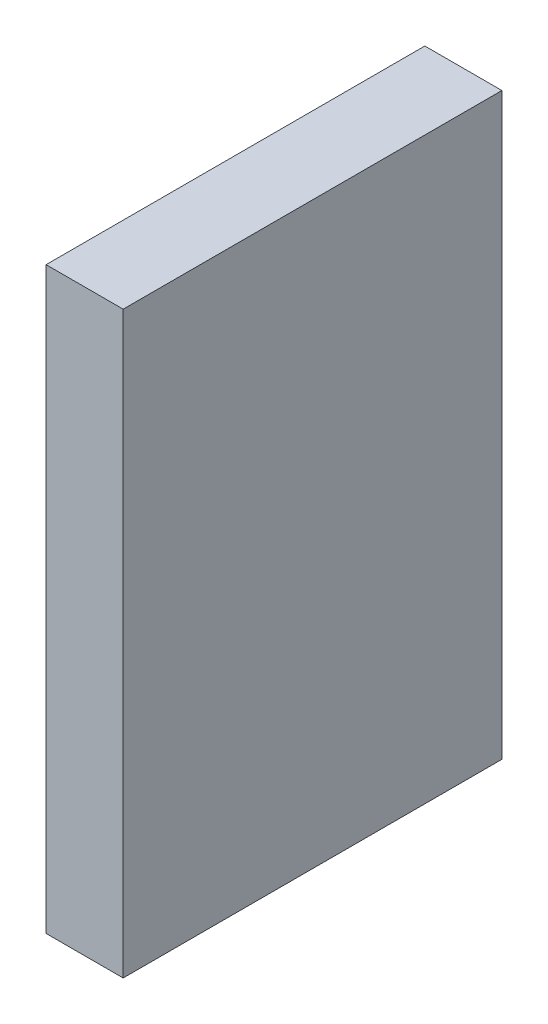
from build123d import *

# Parameters (mm, degrees)
SKETCH1_W           = 215.9
SKETCH1_H           = 330.2
BOSS_EXTRUDE1_DEPTH = 43.942


with BuildPart() as part:
    # Sketch1 → Boss-Extrude1 (new body)
    with BuildSketch(Plane(origin=(0, 0, 0), x_dir=(0, 0, -1), z_dir=(1, 0, 0))):
        with Locations((6.805543478, 46.355)):
            Rectangle(SKETCH1_W, SKETCH1_H)
    extrude(amount=BOSS_EXTRUDE1_DEPTH)


solid = part.part
